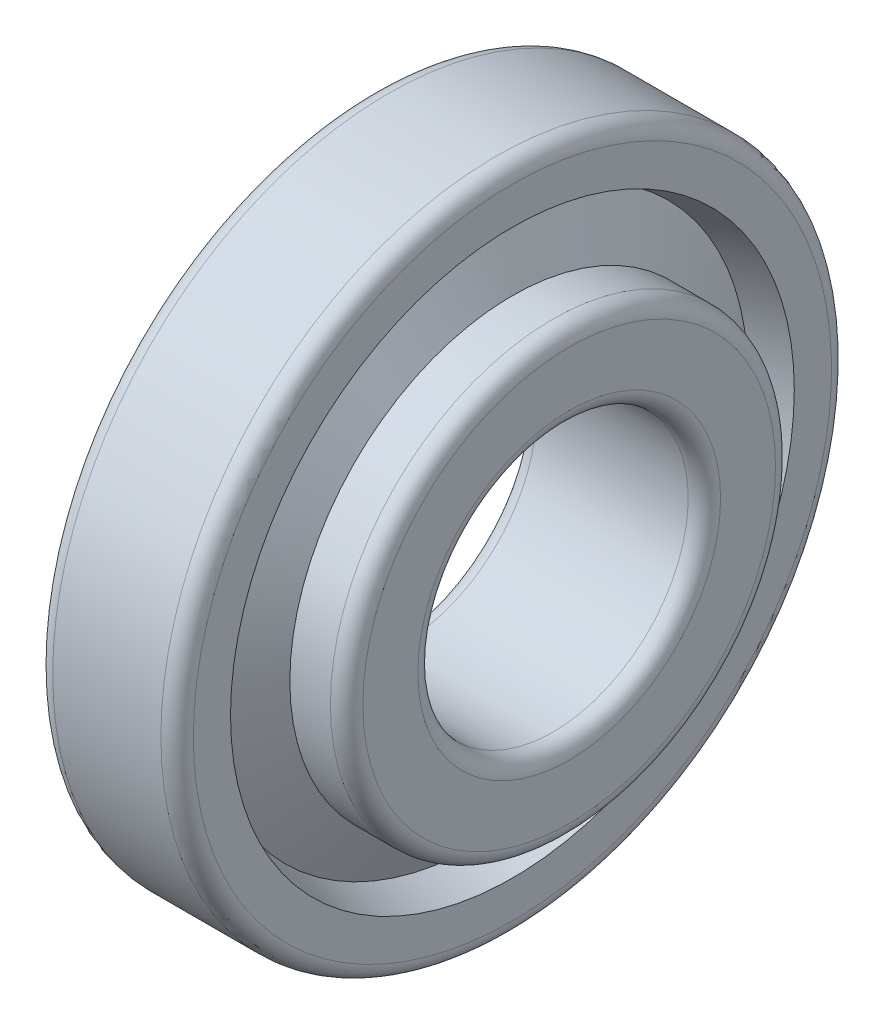
from build123d import *


with BuildPart() as part:
    # Эскиз1 → Повернуть1 (revolve)
    with BuildSketch(Plane.XY):
        with BuildLine():
            Line((5.416057011, 23.730397633), (0, 22.065))
            Line((0, 22.065), (0, 29.5))
            ThreePointArc((0, 29.5), (0.439339828, 30.560660172), (1.5, 31))
            Line((1.5, 31), (11.5, 31))
            ThreePointArc((11.5, 31), (12.560660172, 30.560660172), (13, 29.5))
            Line((13, 29.5), (13, 26.062404234))
            Line((13, 26.062404234), (9.714233768, 25.052055323))
            Line((9.714233768, 25.052055323), (13, 19.077944677))
            Line((13, 19.077944677), (13, 20.577944677))
            Line((13, 20.577944677), (16.75, 20.577944677))
            ThreePointArc((16.75, 20.577944677), (17.810660172, 20.138604849), (18.25, 19.077944677))
            Line((18.25, 19.077944677), (18.25, 14))
            ThreePointArc((18.25, 14), (17.810660172, 12.939339828), (16.75, 12.5))
            Line((16.75, 12.5), (2.75, 12.5))
            ThreePointArc((2.75, 12.5), (1.689339828, 12.939339828), (1.25, 14))
            Line((1.25, 14), (1.25, 16.155760918))
            Line((1.25, 16.155760918), (9.582114021, 16.155760918))
            Line((9.582114021, 16.155760918), (5.416057011, 23.730397633))
        make_face()
    revolve(axis=Axis((-882.527700014, 0, 0), (1, 0, 0)))


solid = part.part
